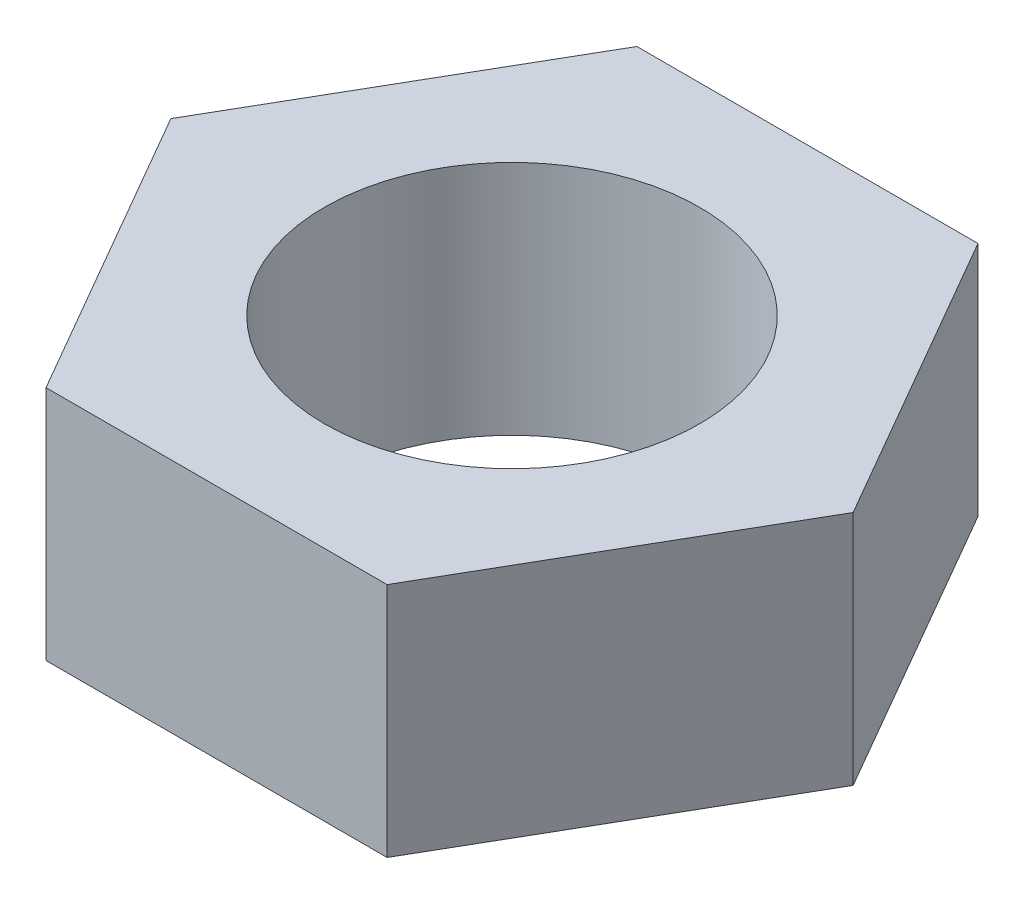
from build123d import *

# Parameters (mm, degrees)
CROQUIS1_R              = 19.05
SALIENTE_EXTRUIR1_DEPTH = 24


with BuildPart() as part:
    # Croquis1 → Saliente-Extruir1 (new body)
    with BuildSketch(Plane(origin=(0, 0, 0), x_dir=(1, 0, 0), z_dir=(0, 1, 0))):
        Polygon((-34.641016151, 0), (-17.320508076, -30), (17.320508076, -30), (34.641016151, 0), (17.320508076, 30), (-17.320508076, 30), align=None)
        Circle(CROQUIS1_R, mode=Mode.SUBTRACT)
    extrude(amount=SALIENTE_EXTRUIR1_DEPTH)


solid = part.part
